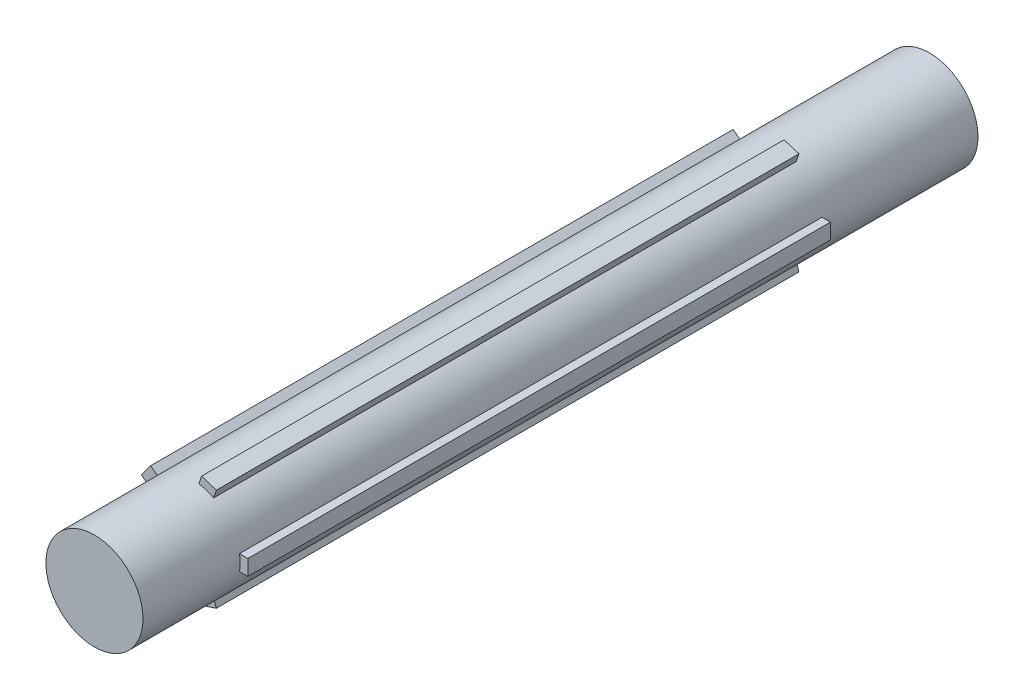
from build123d import *

# Parameters (mm, degrees)
SKETCH1_R           = 12.5
BOSS_EXTRUDE1_DEPTH = 215
BOSS_EXTRUDE2_START = 40
SKETCH1_3_W         = 4
SKETCH1_3_H         = 4
BOSS_EXTRUDE2_DEPTH = 150
CIRPATTERN1_COUNT   = 5


with BuildPart() as part:
    # Sketch1 → Boss-Extrude1 (new body)
    with BuildSketch(Plane.XY):
        Circle(SKETCH1_R)
    extrude(amount=BOSS_EXTRUDE1_DEPTH)

    # Sketch1_3 → Boss-Extrude2 (add)
    with BuildSketch(Plane.XY.offset(BOSS_EXTRUDE2_START)):
        with Locations((12.5, 0)):
            Rectangle(SKETCH1_3_W, SKETCH1_3_H)
    boss_extrude2 = extrude(amount=BOSS_EXTRUDE2_DEPTH)

    # CirPattern1: Boss-Extrude2 ×5 about axis
    cirpattern1_axis = Axis((0, 0, 215), (0, 0, -1))
    for i in range(1, CIRPATTERN1_COUNT):
        add(boss_extrude2.rotate(cirpattern1_axis, i * 360 / CIRPATTERN1_COUNT))


solid = part.part
